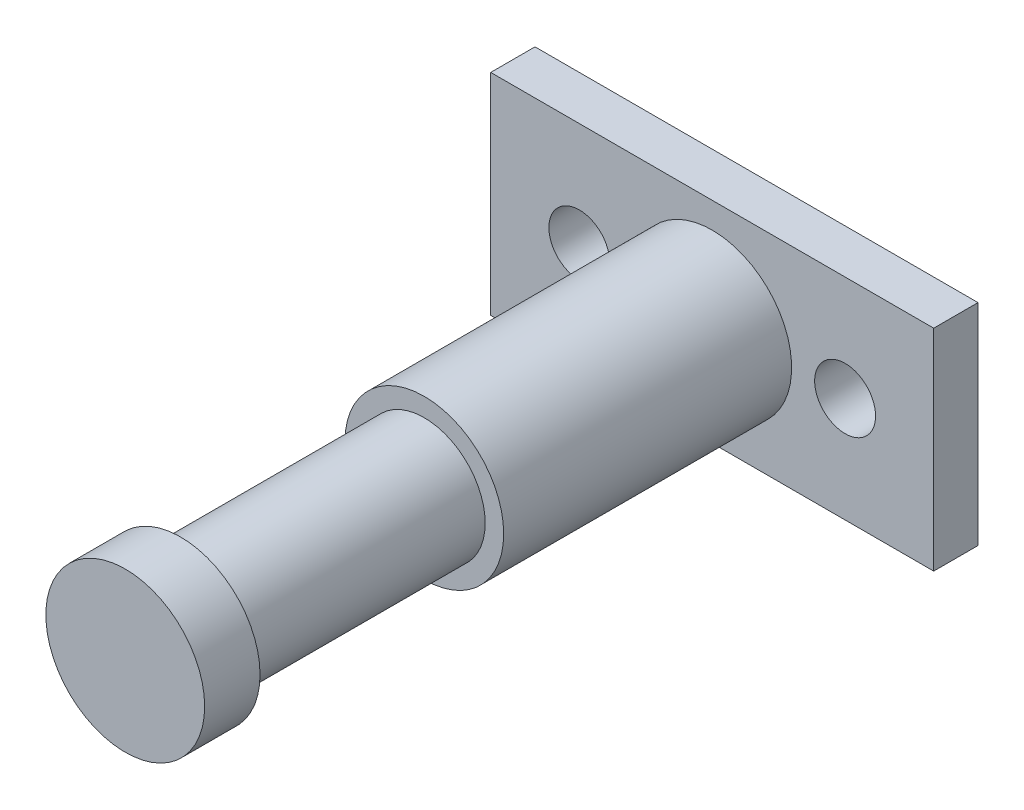
from build123d import *

# Parameters (mm, degrees)
SKETCH1_W           = 40
SKETCH1_H           = 19
SKETCH1_R           = 2.75
BOSS_EXTRUDE1_DEPTH = 4
SKETCH2_R           = 7.1705
BOSS_EXTRUDE2_DEPTH = 26
SKETCH3_R           = 5.5
BOSS_EXTRUDE3_DEPTH = 22
SKETCH4_R           = 7.1705
BOSS_EXTRUDE4_DEPTH = 5


with BuildPart() as part:
    # Sketch1 → Boss-Extrude1 (new body)
    with BuildSketch(Plane.XY):
        Rectangle(SKETCH1_W, SKETCH1_H)
        with Locations((12, 0)):
            Circle(SKETCH1_R, mode=Mode.SUBTRACT)
        with Locations((-12, 0)):
            Circle(SKETCH1_R, mode=Mode.SUBTRACT)
    extrude(amount=-BOSS_EXTRUDE1_DEPTH)

    # Sketch2 → Boss-Extrude2 (add)
    with BuildSketch(Plane.XY):
        Circle(SKETCH2_R)
    extrude(amount=BOSS_EXTRUDE2_DEPTH)

    # Sketch3 → Boss-Extrude3 (add)
    with BuildSketch(Plane.XY.offset(26)):
        Circle(SKETCH3_R)
    extrude(amount=BOSS_EXTRUDE3_DEPTH)

    # Sketch4 → Boss-Extrude4 (add)
    with BuildSketch(Plane.XY.offset(48)):
        Circle(SKETCH4_R)
    extrude(amount=BOSS_EXTRUDE4_DEPTH)


solid = part.part
